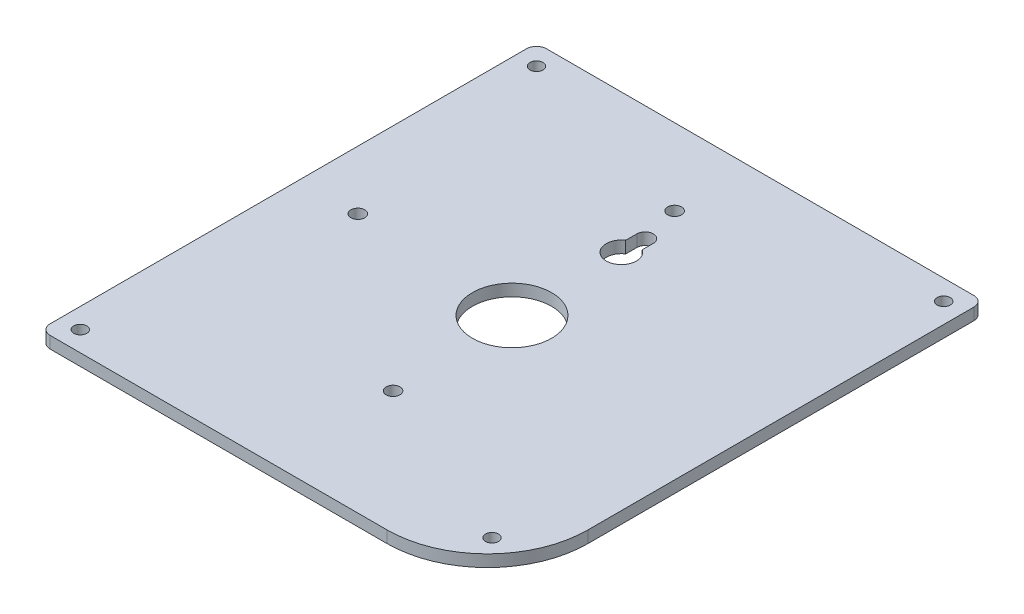
from build123d import *

# Parameters (mm, degrees)
SKETCH1_R           = 1.65
BOSS_EXTRUDE3_DEPTH = 3
CUT_EXTRUDE1_DEPTH  = 4
SKETCH4_R           = 1.75
CUT_EXTRUDE2_DEPTH  = 4
SKETCH5_R           = 10
CUT_EXTRUDE3_DEPTH  = 4
FILLET1_R           = 2.54


with BuildPart() as part:
    # Sketch1 → Boss-Extrude3 (new body)
    with BuildSketch(Plane(origin=(0, 0, 0), x_dir=(1, 0, 0), z_dir=(0, 1, 0))):
        with BuildLine():
            Line((48.284490735, 53.109977813), (-64.735509285, 53.109977813))
            Line((-64.735509285, 53.109977813), (-64.735509285, -72.290076187))
            Line((-64.735509285, -72.290076187), (22.884490735, -72.290076187))
            ThreePointArc((22.884490735, -72.290076187), (40.845002977, -64.850588429), (48.284490735, -46.890076187))
            Line((48.284490735, -46.890076187), (48.284490735, 53.109977813))
        make_face()
        with Locations((-59.655509285, 48.029977813)):
            Circle(SKETCH1_R, mode=Mode.SUBTRACT)
        with Locations((43.204490735, 48.029977813)):
            Circle(SKETCH1_R, mode=Mode.SUBTRACT)
        with Locations((-59.655509285, -67.210076187)):
            Circle(SKETCH1_R, mode=Mode.SUBTRACT)
        with Locations((37.880892571, -60.748479124)):
            Circle(SKETCH1_R, mode=Mode.SUBTRACT)
    extrude(amount=BOSS_EXTRUDE3_DEPTH)

    # Sketch3 → Cut-Extrude1 (cut, through all)
    with BuildSketch(Plane(origin=(0, 3, 0), x_dir=(1, 0, 0), z_dir=(0, 1, 0))):
        with BuildLine():
            Line((-10.308309275, 24.029977813), (-10.308309275, 21.220282526))
            ThreePointArc((-10.308309275, 21.220282526), (-8.225509275, 14.219977813), (-6.142709275, 21.220282526))
            Line((-6.142709275, 21.220282526), (-6.142709275, 24.029977813))
            ThreePointArc((-6.142709275, 24.029977813), (-8.225509275, 26.112777813), (-10.308309275, 24.029977813))
        make_face()
    extrude(amount=-CUT_EXTRUDE1_DEPTH, mode=Mode.SUBTRACT)

    # Sketch4 → Cut-Extrude2 (cut, through all)
    with BuildSketch(Plane(origin=(0, 3, 0), x_dir=(1, 0, 0), z_dir=(0, 1, 0))):
        with Locations((-49.935509285, -6.820022187)):
            Circle(SKETCH4_R)
        with Locations((-6.755509285, -41.110022187)):
            Circle(SKETCH4_R)
        with Locations((-10.565509285, 33.819977813)):
            Circle(SKETCH4_R)
    extrude(amount=-CUT_EXTRUDE2_DEPTH, mode=Mode.SUBTRACT)

    # Sketch5 → Cut-Extrude3 (cut, through all)
    with BuildSketch(Plane(origin=(0, 3, 0), x_dir=(1, 0, 0), z_dir=(0, 1, 0))):
        with Locations((-8.225509275, -9.590049187)):
            Circle(SKETCH5_R)
    extrude(amount=-CUT_EXTRUDE3_DEPTH, mode=Mode.SUBTRACT)

    # Fillet1
    fillet1_edges = [part.edges().sort_by_distance(p)[0] for p in [
        (-64.735509285, 1.5, 72.290076187),
        (-64.735509285, 1.5, -53.109977813),
        (48.284490735, 1.5, -53.109977813),
    ]]
    fillet(fillet1_edges, radius=FILLET1_R)


solid = part.part
